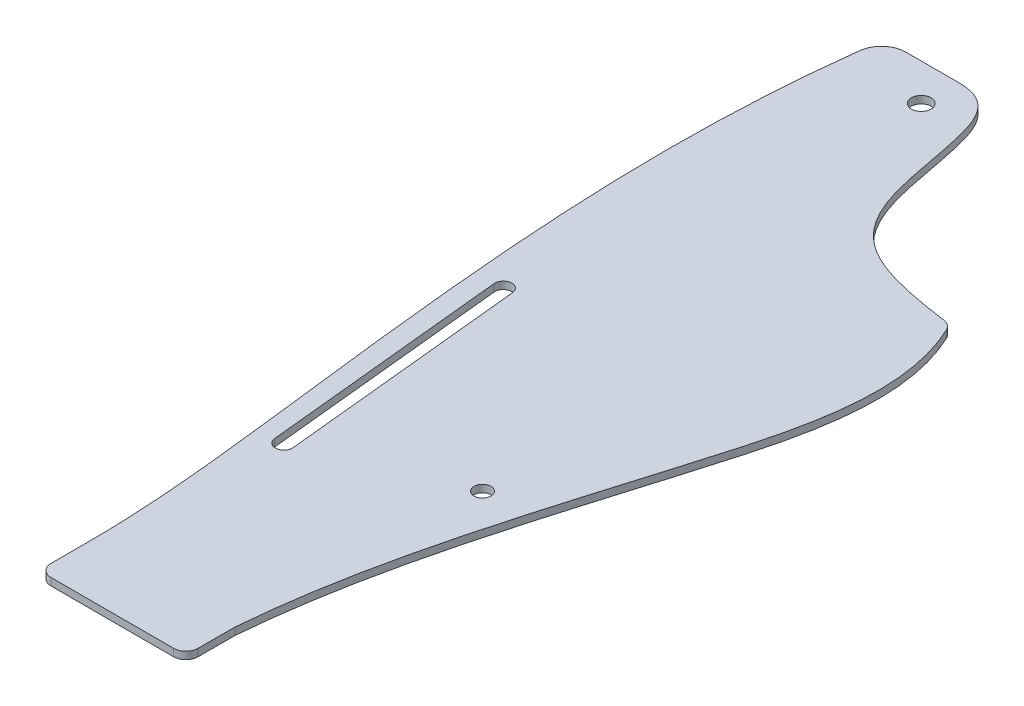
from build123d import *

# Parameters (mm, degrees)
SKETCH1_R           = 4
SKETCH1_R_2         = 3.45
BOSS_EXTRUDE1_DEPTH = 3
FILLET1_R           = 5
FILLET2_R           = 10


with BuildPart() as part:
    # Sketch1 → Boss-Extrude1 (new body)
    with BuildSketch(Plane(origin=(0, 0, 0), x_dir=(1, 0, 0), z_dir=(0, 1, 0))):
        with BuildLine():
            Line((-15, -325), (-15, -345))
            Line((-15, -345), (45, -345))
            Line((45, -345), (45, -325))
            add(Edge.make_bspline(
                [(83.906024568, -72.334193472), (100.067703513, -103.783632704), (75.99628029, -191.959172621), (49.567481947, -271.364145728), (45, -325)],
                knots=[0, 0, 0, 0, 0.388668159, 1, 1, 1, 1], degree=3))
            add(Edge.make_bspline(
                [(0, 15), (11.859468256, 15), (19.027998929, 4.991144095), (28.068840843, -60.357487218), (48.218476882, -67.479548025), (83.906024568, -72.334193472)],
                knots=[0, 0, 0, 0, 0.292385063, 0.473698528, 1, 1, 1, 1], degree=3))
            Line((0, 15), (-30, 15))
            add(Edge.make_bspline(
                [(-30, 15), (-42.027894854, -69.718453242), (-28.647636574, -182.406317953), (-15, -295.84878712), (-15, -325)],
                knots=[0, 0, 0, 0, 0.742442908, 1, 1, 1, 1], degree=3))
        make_face()
        Circle(SKETCH1_R, mode=Mode.SUBTRACT)
        with Locations((47.5, -226.5)):
            Circle(SKETCH1_R_2, mode=Mode.SUBTRACT)
        with BuildLine():
            Line((-13.48245603, -250.35), (-23.48245603, -150.851256289))
            ThreePointArc((-23.48245603, -150.851256289), (-20.35, -147.018800259), (-16.51754397, -150.151256289))
            Line((-16.51754397, -150.151256289), (-6.51754397, -249.65))
            ThreePointArc((-6.51754397, -249.65), (-9.65, -253.48245603), (-13.48245603, -250.35))
        make_face(mode=Mode.SUBTRACT)
    extrude(amount=BOSS_EXTRUDE1_DEPTH)

    # Fillet1
    fillet1_edges = [part.edges().sort_by_distance(p)[0] for p in [
        (83.906024568, 1.5, 72.334193472),
        (45, 1.5, 345),
        (-15, 1.5, 345),
    ]]
    fillet(fillet1_edges, radius=FILLET1_R)

    # Fillet2
    fillet2_edges = [part.edges().sort_by_distance(p)[0] for p in [
        (-30, 1.5, -15),
    ]]
    fillet(fillet2_edges, radius=FILLET2_R)


solid = part.part
